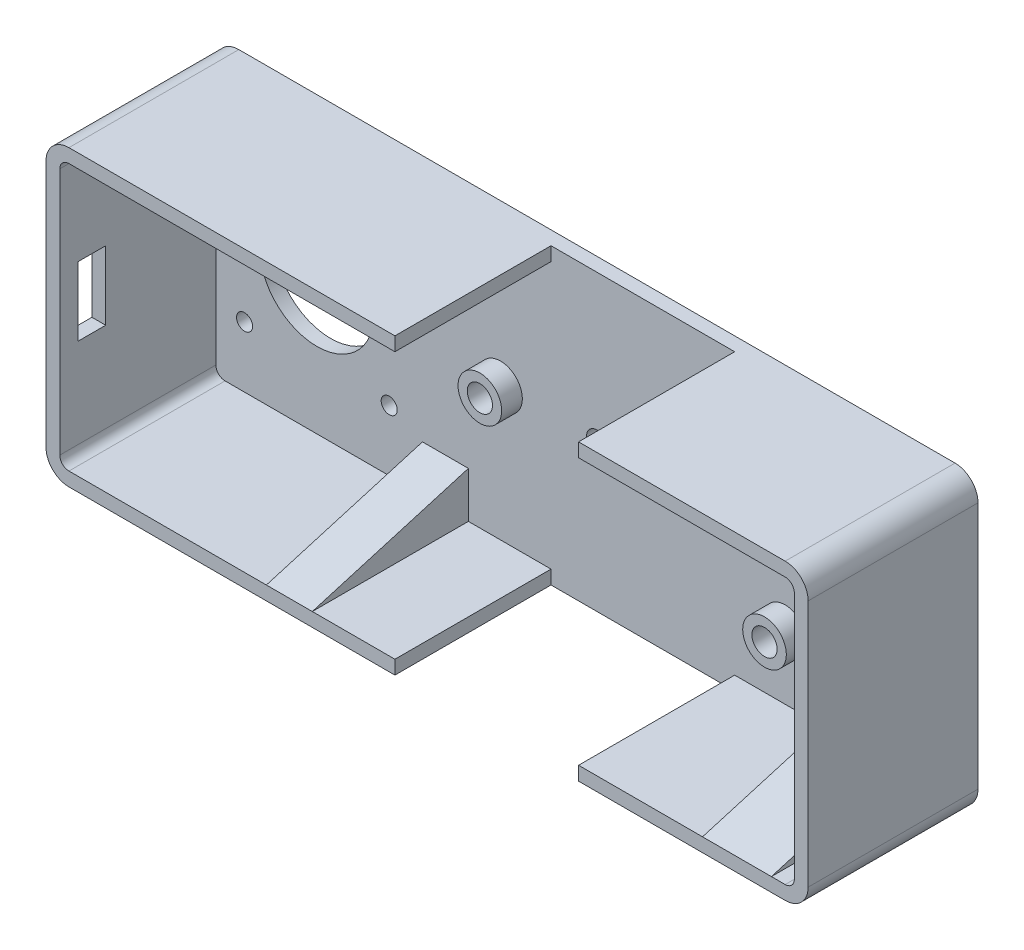
from build123d import *

# Parameters (mm, degrees)
BOSS_EXTRUDE1_DEPTH = 37
SKETCH2_R           = 1.75
SKETCH2_R_2         = 12.5
SKETCH2_R_3         = 2.75
SKETCH2_R_4         = 2.25
CUT_EXTRUDE1_DEPTH  = 38
SKETCH5_R           = 2.25
CUT_EXTRUDE2_DEPTH  = 38
CUT_EXTRUDE3_DEPTH  = 34
SKETCH7_R           = 4.75
BOSS_EXTRUDE2_DEPTH = 4.5
SKETCH10_W          = 40
SKETCH10_H          = 64
CUT_EXTRUDE4_DEPTH  = 34
SKETCH11_R          = 2.75
CUT_EXTRUDE5_DEPTH  = 8.5
SKETCH12_W          = 15
SKETCH12_H          = 10
SKETCH12_W_2        = 20
SKETCH12_W_3        = 10
BOSS_EXTRUDE3_DEPTH = 34
CUT_EXTRUDE6_DEPTH  = 33
CUT_EXTRUDE8_DEPTH  = 15
CUT_EXTRUDE9_DEPTH  = 15
CUT_EXTRUDE10_DEPTH = 10
CUT_EXTRUDE11_DEPTH = 10
SKETCH20_W          = 6
SKETCH20_H          = 15
CUT_EXTRUDE12_DEPTH = 3


with BuildPart() as part:
    # Sketch1 → Boss-Extrude1 (new body)
    with BuildSketch(Plane.XY):
        with BuildLine():
            Line((-78, 32), (78, 32))
            ThreePointArc((78, 32), (81.535533906, 30.535533906), (83, 27))
            Line((83, 27), (83, -27))
            ThreePointArc((83, -27), (81.535533906, -30.535533906), (78, -32))
            Line((78, -32), (-78, -32))
            ThreePointArc((-78, -32), (-81.535533906, -30.535533906), (-83, -27))
            Line((-83, -27), (-83, 27))
            ThreePointArc((-83, 27), (-81.535533906, 30.535533906), (-78, 32))
        make_face()
    extrude(amount=BOSS_EXTRUDE1_DEPTH)

    # Sketch2 → Cut-Extrude1 (cut, through all)
    with BuildSketch(Plane.XY.offset(37)):
        with Locations((-73.75, 15.75)):
            Circle(SKETCH2_R)
        with Locations((-42.25, 15.75)):
            Circle(SKETCH2_R)
        with Locations((-73.75, -15.75)):
            Circle(SKETCH2_R)
        with Locations((-42.25, -15.75)):
            Circle(SKETCH2_R)
        with Locations((-58, 0)):
            Circle(SKETCH2_R_2)
        with Locations((44, 15)):
            Circle(SKETCH2_R_3)
        with Locations((44, -15)):
            Circle(SKETCH2_R_3)
        with Locations((-18, 0)):
            Circle(SKETCH2_R_3)
        with Locations((64, 0)):
            Circle(SKETCH2_R_4)
    extrude(amount=-CUT_EXTRUDE1_DEPTH, mode=Mode.SUBTRACT)

    # Sketch5 → Cut-Extrude2 (cut, through all)
    with BuildSketch(Plane.XY.offset(37)):
        with Locations((3, 0)):
            Circle(SKETCH5_R)
        with Locations((23, 0)):
            Circle(SKETCH5_R)
    extrude(amount=-CUT_EXTRUDE2_DEPTH, mode=Mode.SUBTRACT)

    # Sketch6 → Cut-Extrude3 (cut)
    with BuildSketch(Plane.XY.offset(37)):
        with BuildLine():
            Line((-78, -29), (78, -29))
            ThreePointArc((78, -29), (79.414213562, -28.414213562), (80, -27))
            Line((80, -27), (80, 27))
            ThreePointArc((80, 27), (79.414213562, 28.414213562), (78, 29))
            Line((78, 29), (-78, 29))
            ThreePointArc((-78, 29), (-79.414213562, 28.414213562), (-80, 27))
            Line((-80, 27), (-80, -27))
            ThreePointArc((-80, -27), (-79.414213562, -28.414213562), (-78, -29))
        make_face()
    extrude(amount=-CUT_EXTRUDE3_DEPTH, mode=Mode.SUBTRACT)

    # Sketch7 → Boss-Extrude2 (add)
    with BuildSketch(Plane.XY.offset(3)):
        with Locations((-18, 0)):
            Circle(SKETCH7_R)
        with Locations((44, -15)):
            Circle(SKETCH7_R)
        with Locations((44, 15)):
            Circle(SKETCH7_R)
    extrude(amount=BOSS_EXTRUDE2_DEPTH)

    # Sketch10 → Cut-Extrude4 (cut)
    with BuildSketch(Plane.XY.offset(37)):
        with Locations((13, 0)):
            Rectangle(SKETCH10_W, SKETCH10_H)
    extrude(amount=-CUT_EXTRUDE4_DEPTH, mode=Mode.SUBTRACT)

    # Sketch11 → Cut-Extrude5 (cut, through all)
    with BuildSketch(Plane.XY.offset(7.5)):
        with Locations((44, -15)):
            Circle(SKETCH11_R)
        with Locations((-18, 0)):
            Circle(SKETCH11_R)
        with Locations((44, 15)):
            Circle(SKETCH11_R)
    extrude(amount=-CUT_EXTRUDE5_DEPTH, mode=Mode.SUBTRACT)

    # Sketch12 → Boss-Extrude3 (add, through all)
    with BuildSketch(Plane.XY.offset(3)):
        with Locations((67.5, -24)):
            Rectangle(SKETCH12_W, SKETCH12_H)
        with Locations((67.5, 24)):
            Rectangle(SKETCH12_W, SKETCH12_H)
        with Locations((70, -11)):
            Rectangle(SKETCH12_W_2, SKETCH12_H)
        with Locations((70, 11)):
            Rectangle(SKETCH12_W_2, SKETCH12_H)
        with Locations((-30, -24)):
            Rectangle(SKETCH12_W_3, SKETCH12_H)
        with Locations((-30, 24)):
            Rectangle(SKETCH12_W_3, SKETCH12_H)
    extrude(amount=BOSS_EXTRUDE3_DEPTH)

    # Sketch14 → Cut-Extrude6 (cut)
    with BuildSketch(Plane.XZ.offset(16)):
        Polygon((80, 37), (60, 37), (60, 3), align=None)
    extrude(amount=-CUT_EXTRUDE6_DEPTH, mode=Mode.SUBTRACT)

    # Sketch16 → Cut-Extrude8 (cut)
    with BuildSketch(Plane(origin=(75, 0, 0), x_dir=(0, 0, -1), z_dir=(1, 0, 0))):
        Polygon((-37, -19), (-3, -19), (-37, -29), align=None)
    extrude(amount=-CUT_EXTRUDE8_DEPTH, mode=Mode.SUBTRACT)

    # Sketch17 → Cut-Extrude9 (cut)
    with BuildSketch(Plane.ZY.offset(-60)):
        Polygon((37, 19), (3, 19), (37, 29), align=None)
    extrude(amount=-CUT_EXTRUDE9_DEPTH, mode=Mode.SUBTRACT)

    # Sketch18 → Cut-Extrude10 (cut)
    with BuildSketch(Plane(origin=(-25, 0, 0), x_dir=(0, 0, -1), z_dir=(1, 0, 0))):
        Polygon((-37, -29), (-37, -19), (-3, -19), align=None)
    extrude(amount=-CUT_EXTRUDE10_DEPTH, mode=Mode.SUBTRACT)

    # Sketch19 → Cut-Extrude11 (cut)
    with BuildSketch(Plane(origin=(-25, 0, 0), x_dir=(0, 0, -1), z_dir=(1, 0, 0))):
        Polygon((-37, 29), (-3, 19), (-37, 19), align=None)
    extrude(amount=-CUT_EXTRUDE11_DEPTH, mode=Mode.SUBTRACT)

    # Sketch20 → Cut-Extrude12 (cut)
    with BuildSketch(Plane.ZY.offset(83)):
        with Locations((30, 0)):
            Rectangle(SKETCH20_W, SKETCH20_H)
    extrude(amount=-CUT_EXTRUDE12_DEPTH, mode=Mode.SUBTRACT)


solid = part.part
